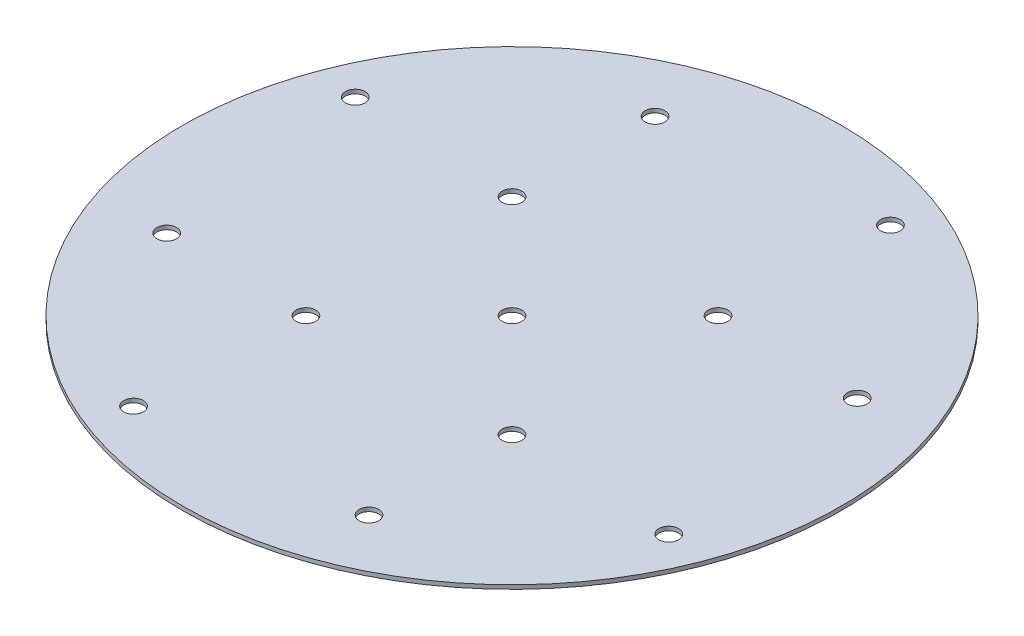
from build123d import *

# Parameters (mm, degrees)
SKETCH2_W                    = 82.55
SKETCH2_H                    = 1
F_10_0_1935_DIAMETER_HOLE1_D = 4.9149
CIRPATTERN3_COUNT            = 4
F_10_0_1935_DIAMETER_HOLE2_D = 4.9149


with BuildPart() as part:
    # Sketch2 → Revolve1 (revolve)
    with BuildSketch(Plane(origin=(0, 0, 0), x_dir=(0, 0, -1), z_dir=(1, 0, 0))):
        with Locations((-41.275, 0.5)):
            Rectangle(SKETCH2_W, SKETCH2_H)
    revolve(axis=Axis((0, -0.05, 0), (0, 1, 0)))

    # #10 (0.1935) Diameter Hole1 (through all)
    with Locations(Plane(origin=(0, 1, 0), x_dir=(1, 0, 0), z_dir=(0, 1, 0))):
        with Locations((-25.333643223, 61.160825052), (264.743675233, 73.787758551), (-67.027460084, 27.763683018), (-25.809397513, 25.809397513)):
            f_10_0_1935_diameter_hole1 = Hole(F_10_0_1935_DIAMETER_HOLE1_D / 2)

    # CirPattern3: #10 (0.1935) Diameter Hole1 ×4 about axis
    cirpattern3_axis = Axis((0, 0, 0), (0, 1, 0))
    for i in range(1, CIRPATTERN3_COUNT):
        add(f_10_0_1935_diameter_hole1.rotate(cirpattern3_axis, i * 360 / CIRPATTERN3_COUNT), mode=Mode.SUBTRACT)

    # #10 (0.1935) Diameter Hole2 (through all)
    with Locations(Plane(origin=(0, 1, 0), x_dir=(1, 0, 0), z_dir=(0, 1, 0))):
        with Locations((0, 0)):
            Hole(F_10_0_1935_DIAMETER_HOLE2_D / 2)


solid = part.part
